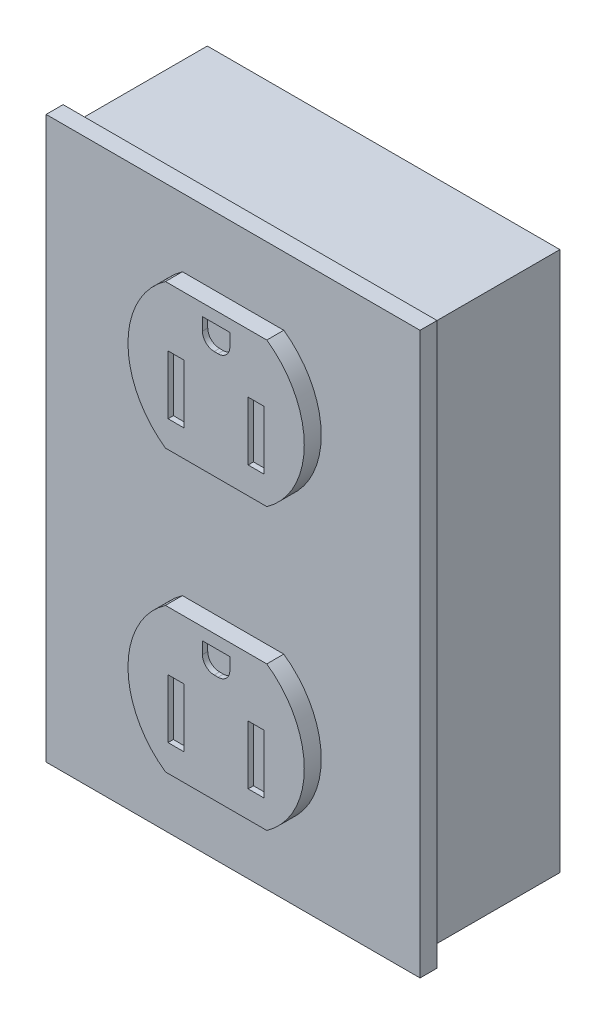
from build123d import *

# Parameters (mm, degrees)
CROQUIS1_W              = 70
CROQUIS1_H              = 105
SALIENTE_EXTRUIR1_DEPTH = 3.175
CROQUIS2_R              = 16.5
SALIENTE_EXTRUIR2_DEPTH = 3.175
CROQUIS3_W              = 26
CROQUIS3_H              = 6
CORTAR_EXTRUIR1_DEPTH   = 3.175
CROQUIS4_W              = 3
CROQUIS4_H              = 11
CORTAR_EXTRUIR2_DEPTH   = 1
CROQUIS5_W              = 66
CROQUIS5_H              = 101
SALIENTE_EXTRUIR3_DEPTH = 25


with BuildPart() as part:
    # Croquis1 → Saliente-Extruir1 (new body)
    with BuildSketch(Plane.XY):
        with Locations((35, -52.5)):
            Rectangle(CROQUIS1_W, CROQUIS1_H)
    extrude(amount=SALIENTE_EXTRUIR1_DEPTH)

    # Croquis2 → Saliente-Extruir2 (add)
    with BuildSketch(Plane.XY.offset(3.175)):
        with Locations((35, -26.25)):
            Circle(CROQUIS2_R)
        with Locations((35, -78.75)):
            Circle(CROQUIS2_R)
    extrude(amount=SALIENTE_EXTRUIR2_DEPTH)

    # Croquis3 → Cortar-Extruir1 (cut)
    with BuildSketch(Plane.XY.offset(6.35)):
        with Locations((35, -9.75)):
            Rectangle(CROQUIS3_W, CROQUIS3_H)
        with Locations((35, -42.75)):
            Rectangle(CROQUIS3_W, CROQUIS3_H)
        with Locations((35, -62.25)):
            Rectangle(CROQUIS3_W, CROQUIS3_H)
        with Locations((35, -95.25)):
            Rectangle(CROQUIS3_W, CROQUIS3_H)
    extrude(amount=-CORTAR_EXTRUIR1_DEPTH, mode=Mode.SUBTRACT)

    # Croquis4 → Cortar-Extruir2 (cut)
    with BuildSketch(Plane.XY.offset(6.35)):
        with Locations((27.5, -29.25)):
            Rectangle(CROQUIS4_W, CROQUIS4_H)
        with Locations((42.5, -29.25)):
            Rectangle(CROQUIS4_W, CROQUIS4_H)
        with BuildLine():
            Line((34.632057675, -19.532945654), (35.367942325, -19.532945654))
            ThreePointArc((35.367942325, -19.532945654), (36.923577244, -18.888580572), (37.567942325, -17.332945654))
            Line((37.567942325, -17.332945654), (37.567942325, -14.967054346))
            Line((37.567942325, -14.967054346), (32.432057675, -14.967054346))
            Line((32.432057675, -14.967054346), (32.432057675, -17.332945654))
            ThreePointArc((32.432057675, -17.332945654), (33.076422756, -18.888580572), (34.632057675, -19.532945654))
        make_face()
        with Locations((42.5, -81.75)):
            Rectangle(CROQUIS4_W, CROQUIS4_H)
        with Locations((27.5, -81.75)):
            Rectangle(CROQUIS4_W, CROQUIS4_H)
        with BuildLine():
            Line((34.632057675, -71.973579429), (35.367942325, -71.973579429))
            ThreePointArc((35.367942325, -71.973579429), (36.923577244, -71.329214348), (37.567942325, -69.773579429))
            Line((37.567942325, -69.773579429), (37.567942325, -67.526420571))
            Line((37.567942325, -67.526420571), (32.432057675, -67.526420571))
            Line((32.432057675, -67.526420571), (32.432057675, -69.773579429))
            ThreePointArc((32.432057675, -69.773579429), (33.076422756, -71.329214348), (34.632057675, -71.973579429))
        make_face()
    extrude(amount=-CORTAR_EXTRUIR2_DEPTH, mode=Mode.SUBTRACT)

    # Croquis5 → Saliente-Extruir3 (add)
    with BuildSketch(Plane(origin=(0, 0, 0), x_dir=(-1, 0, 0), z_dir=(0, 0, -1))):
        with Locations((-35, -52.5)):
            Rectangle(CROQUIS5_W, CROQUIS5_H)
    extrude(amount=SALIENTE_EXTRUIR3_DEPTH)


solid = part.part
